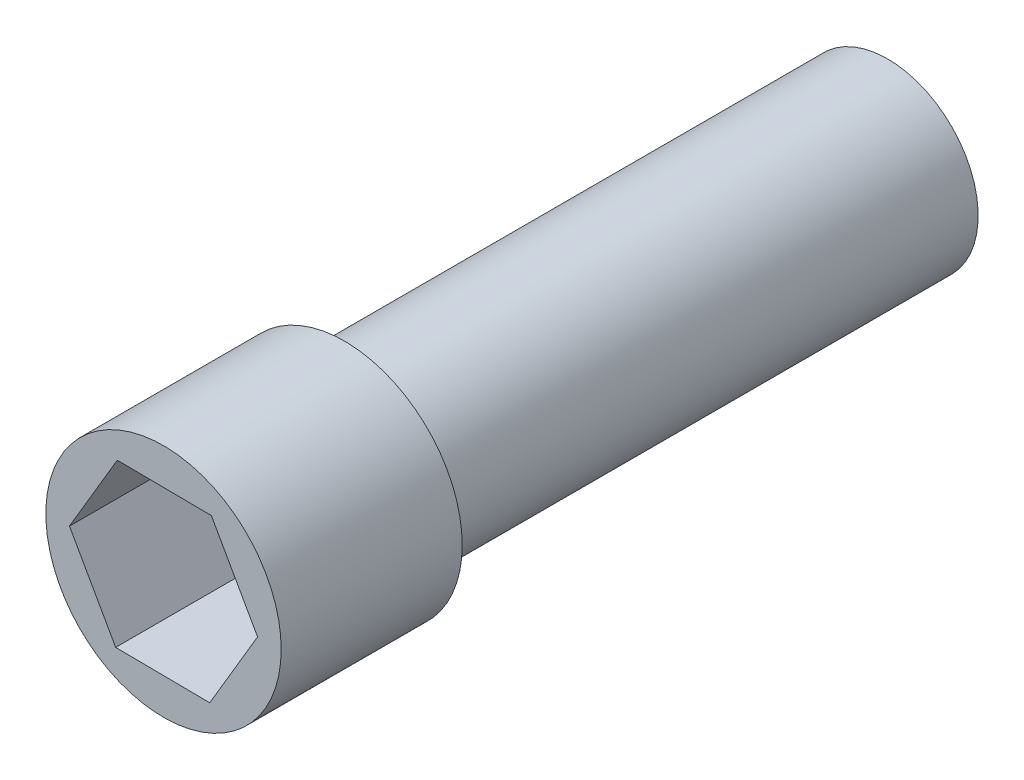
from build123d import *

# Parameters (mm, degrees)
SKETCH1_R           = 6.5
BOSS_EXTRUDE1_DEPTH = 10
SKETCH2_R           = 5
BOSS_EXTRUDE2_DEPTH = 30
CUT_EXTRUDE1_DEPTH  = 9


with BuildPart() as part:
    # Sketch1 → Boss-Extrude1 (new body)
    with BuildSketch(Plane.XY):
        Circle(SKETCH1_R)
    extrude(amount=-BOSS_EXTRUDE1_DEPTH)

    # Sketch2 → Boss-Extrude2 (add)
    with BuildSketch(Plane(origin=(0, 0, -10), x_dir=(-1, 0, 0), z_dir=(0, 0, -1))):
        Circle(SKETCH2_R)
    extrude(amount=BOSS_EXTRUDE2_DEPTH)

    # Sketch3 → Cut-Extrude1 (cut)
    with BuildSketch(Plane.XY):
        Polygon((-2.552781944, 4.525848467), (-5.195890718, 0.052150219), (-2.643108774, -4.473698247), (2.552781944, -4.525848467), (5.195890718, -0.052150219), (2.643108774, 4.473698247), align=None)
    extrude(amount=-CUT_EXTRUDE1_DEPTH, mode=Mode.SUBTRACT)


solid = part.part
